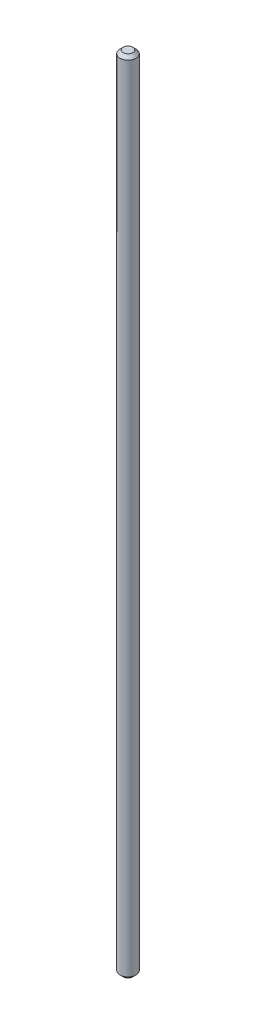
from build123d import *

# Parameters (mm, degrees)
ESQUISSE1_R        = 2.5
BOSS_EXTRU_1_DEPTH = 250
CHANFREIN1_SIZE    = 1


with BuildPart() as part:
    # Esquisse1 → Boss.-Extru.1 (new body)
    with BuildSketch(Plane(origin=(0, 0, 0), x_dir=(1, 0, 0), z_dir=(0, 1, 0))):
        Circle(ESQUISSE1_R)
    extrude(amount=BOSS_EXTRU_1_DEPTH)

    # Chanfrein1
    chanfrein1_edges = [part.edges().sort_by_distance(p)[0] for p in [
        (-2.5, 0, 0),
        (-2.5, 250, 0),
    ]]
    chamfer(chanfrein1_edges, length=CHANFREIN1_SIZE)


solid = part.part
